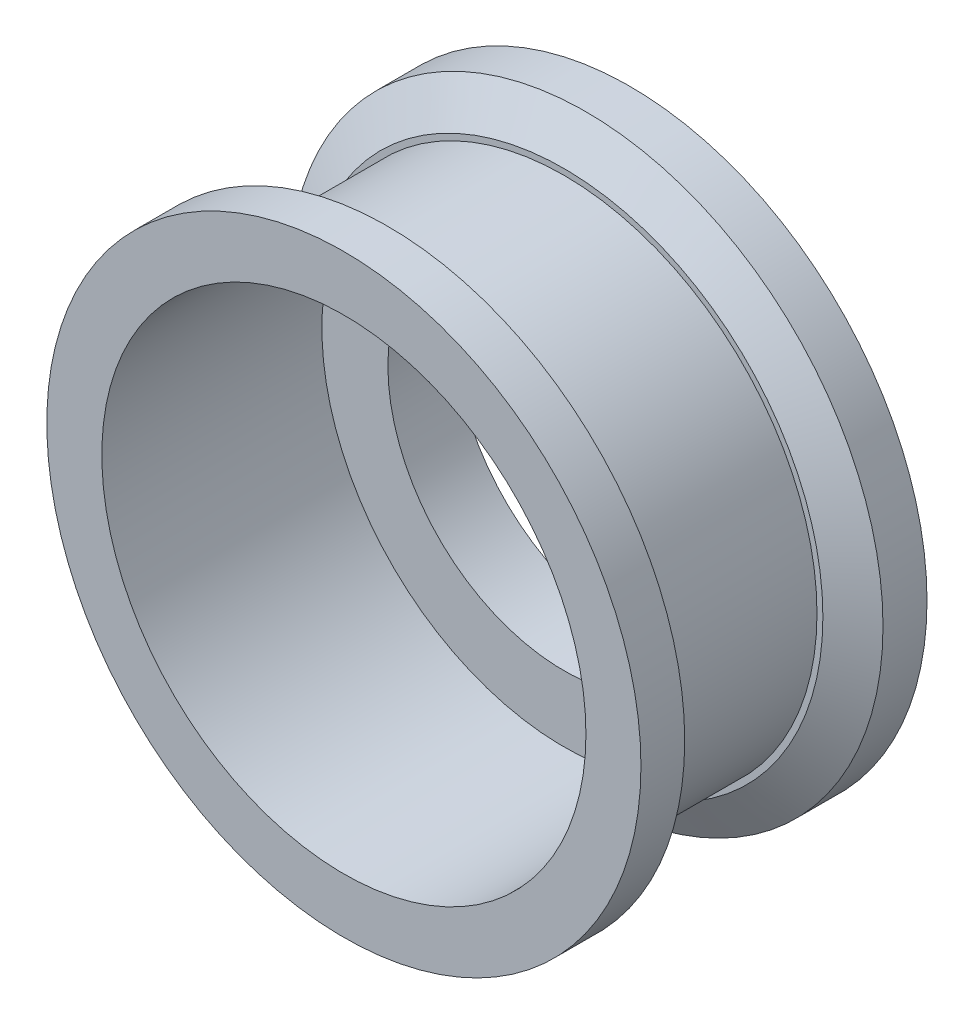
from build123d import *

# Parameters (mm, degrees)
SKETCH1_R           = 13.5
SKETCH1_R_2         = 8
BOSS_EXTRUDE1_DEPTH = 13
SKETCH2_R           = 11
CUT_EXTRUDE1_DEPTH  = 10
CUT_EXTRUDE2_START  = -3
SKETCH3_OUTSIDE_W   = 37.068
SKETCH3_OUTSIDE_H   = 37.068
SKETCH3_OUTSIDE_R   = 11.5
CUT_EXTRUDE2_DEPTH  = 7
CHAMFER1_SIZE       = 1.75
CHAMFER1_SIZE2      = 1.010362971
CHAMFER2_SIZE       = 1
CHAMFER2_SIZE2      = 1.732050808


with BuildPart() as part:
    # Sketch1 → Boss-Extrude1 (new body)
    with BuildSketch(Plane.XY):
        Circle(SKETCH1_R)
        Circle(SKETCH1_R_2, mode=Mode.SUBTRACT)
    extrude(amount=BOSS_EXTRUDE1_DEPTH)

    # Sketch2 → Cut-Extrude1 (cut)
    with BuildSketch(Plane.XY.offset(13)):
        Circle(SKETCH2_R)
    extrude(amount=-CUT_EXTRUDE1_DEPTH, mode=Mode.SUBTRACT)

    # Sketch3 outside → Cut-Extrude2 (cut)
    with BuildSketch(Plane.XY.offset(13).offset(CUT_EXTRUDE2_START)):
        Rectangle(SKETCH3_OUTSIDE_W, SKETCH3_OUTSIDE_H)
        Circle(SKETCH3_OUTSIDE_R, mode=Mode.SUBTRACT)
    extrude(amount=-CUT_EXTRUDE2_DEPTH, mode=Mode.SUBTRACT)

    # Chamfer1
    chamfer1_edges = [part.edges().sort_by_distance(p)[0] for p in [
        (-13.5, 0, 10),
    ]]
    chamfer1_side = [part.faces().sort_by_distance(p)[0] for p in [
        (-13.118162338, 0, 10),
    ]]
    chamfer(chamfer1_edges, length=CHAMFER1_SIZE, length2=CHAMFER1_SIZE2, reference=chamfer1_side[0])

    # Chamfer2
    chamfer2_edges = [part.edges().sort_by_distance(p)[0] for p in [
        (-13.5, 0, 3),
    ]]
    chamfer2_side = [part.faces().sort_by_distance(p)[0] for p in [
        (-13.5, 0, 1.5),
    ]]
    chamfer(chamfer2_edges, length=CHAMFER2_SIZE, length2=CHAMFER2_SIZE2, reference=chamfer2_side[0])


solid = part.part
